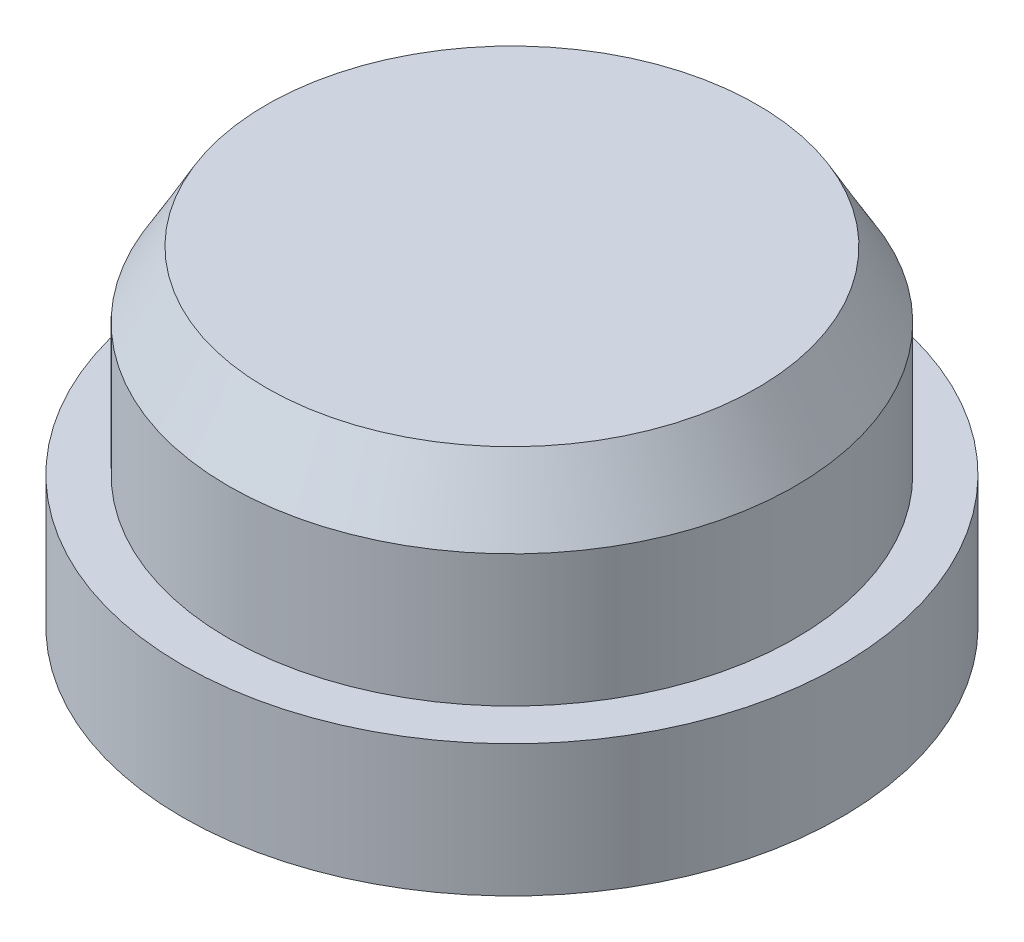
from build123d import *

# Parameters (mm, degrees)
SKETCH1_R           = 5
BOSS_EXTRUDE1_DEPTH = 2
SKETCH2_R           = 4.3
BOSS_EXTRUDE2_DEPTH = 3
CHAMFER1_SIZE       = 1
CHAMFER1_SIZE2      = 0.577350269


with BuildPart() as part:
    # Sketch1 → Boss-Extrude1 (new body)
    with BuildSketch(Plane(origin=(0, 0, 0), x_dir=(1, 0, 0), z_dir=(0, 1, 0))):
        Circle(SKETCH1_R)
    extrude(amount=BOSS_EXTRUDE1_DEPTH)

    # Sketch2 → Boss-Extrude2 (add)
    with BuildSketch(Plane(origin=(0, 2, 0), x_dir=(1, 0, 0), z_dir=(0, 1, 0))):
        Circle(SKETCH2_R)
    extrude(amount=BOSS_EXTRUDE2_DEPTH)

    # Chamfer1
    chamfer1_edges = [part.edges().sort_by_distance(p)[0] for p in [
        (-4.3, 5, 0),
    ]]
    chamfer1_side = [part.faces().sort_by_distance(p)[0] for p in [
        (-4.3, 3.5, 0),
    ]]
    chamfer(chamfer1_edges, length=CHAMFER1_SIZE, length2=CHAMFER1_SIZE2, reference=chamfer1_side[0])


solid = part.part
